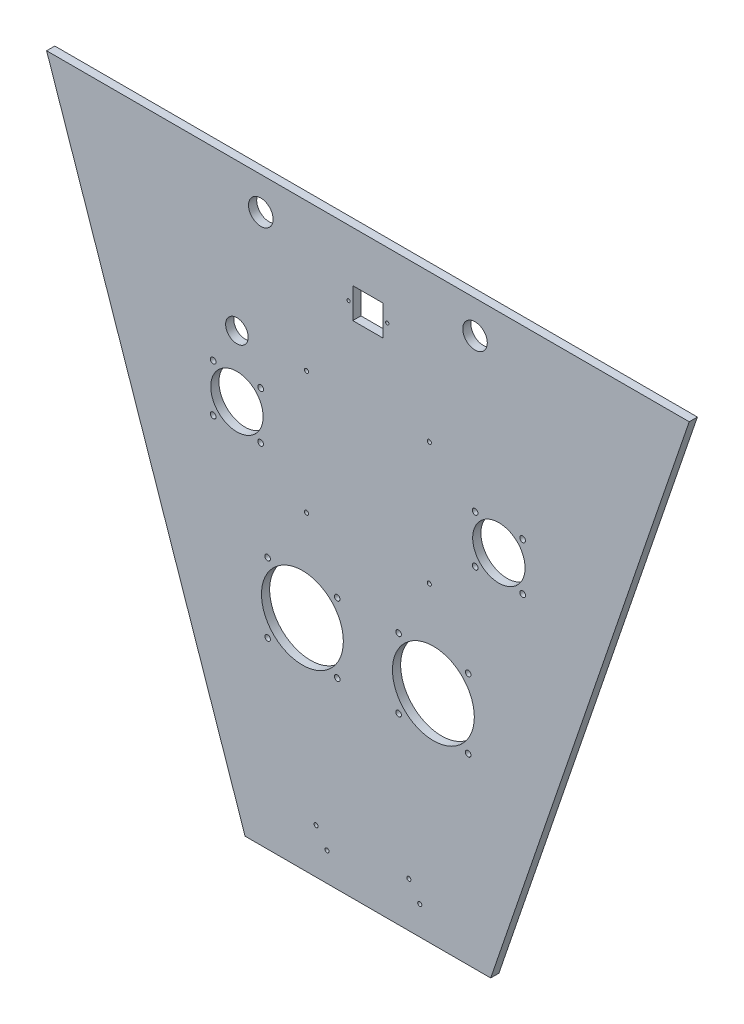
from build123d import *

# Parameters (mm, degrees)
BOSS_EXTRUDE1_DEPTH = 6.35
SKETCH2_R           = 1.5875
SKETCH2_W           = 23.495
SKETCH2_H           = 23.495
SKETCH2_R_2         = 8.763
SKETCH2_R_3         = 1.27
SKETCH2_R_4         = 2.159
SKETCH2_R_5         = 2.2225
SKETCH2_R_6         = 31.75
SKETCH2_R_7         = 20.32
SKETCH2_R_8         = 9.525
CUT_EXTRUDE1_DEPTH  = 7.35


with BuildPart() as part:
    # Sketch1 → Boss-Extrude1 (new body)
    with BuildSketch(Plane.XY):
        Polygon((-249.2375, 225.334147625), (249.2375, 225.334147625), (95.25, -225.334147625), (-95.25, -225.334147625), align=None)
    extrude(amount=BOSS_EXTRUDE1_DEPTH)

    # Sketch2 → Cut-Extrude1 (cut, through all)
    with BuildSketch(Plane.XY.offset(6.35)):
        with Locations((-47.625, 15.784147625)):
            Circle(SKETCH2_R)
        with Locations((-47.625, 111.034147625)):
            Circle(SKETCH2_R)
        with Locations((47.625, 15.784147625)):
            Circle(SKETCH2_R)
        with Locations((47.625, 111.034147625)):
            Circle(SKETCH2_R)
        with Locations((0, 174.534147625)):
            Rectangle(SKETCH2_W, SKETCH2_H)
        with Locations((-101.6, 111.034147625)):
            Circle(SKETCH2_R_2)
        with Locations((15, 174.534147625)):
            Circle(SKETCH2_R_3)
        with Locations((-15, 174.534147625)):
            Circle(SKETCH2_R_3)
        with Locations((-40.216666667, -190.409147625)):
            Circle(SKETCH2_R)
        with Locations((-31.75, -203.109147625)):
            Circle(SKETCH2_R)
        with Locations((31.75, -190.409147625)):
            Circle(SKETCH2_R)
        with Locations((40.216666667, -203.109147625)):
            Circle(SKETCH2_R)
        with Locations((-77.7875, -29.409256694)):
            Circle(SKETCH2_R_4)
        with Locations((-23.8125, -29.409256694)):
            Circle(SKETCH2_R_4)
        with Locations((-77.7875, -83.384256694)):
            Circle(SKETCH2_R_4)
        with Locations((-23.8125, -83.384256694)):
            Circle(SKETCH2_R_4)
        with Locations((-83.185, 44.994147625)):
            Circle(SKETCH2_R_5)
        with Locations((-50.8, -56.396756694)):
            Circle(SKETCH2_R_6)
        with Locations((-120.015, 44.994147625)):
            Circle(SKETCH2_R_5)
        with Locations((-120.015, 81.824147625)):
            Circle(SKETCH2_R_5)
        with Locations((-83.185, 81.824147625)):
            Circle(SKETCH2_R_5)
        with Locations((-101.6, 63.409147625)):
            Circle(SKETCH2_R_7)
        with Locations((120.015, 44.994147625)):
            Circle(SKETCH2_R_5)
        with Locations((83.185, 44.994147625)):
            Circle(SKETCH2_R_5)
        with Locations((83.185, 81.824147625)):
            Circle(SKETCH2_R_5)
        with Locations((-83.079166667, 199.934147625)):
            Circle(SKETCH2_R_8)
        with Locations((83.079166667, 199.934147625)):
            Circle(SKETCH2_R_8)
        with Locations((120.015, 81.824147625)):
            Circle(SKETCH2_R_5)
        with Locations((101.6, 63.409147625)):
            Circle(SKETCH2_R_7)
        with Locations((23.8125, -29.409256694)):
            Circle(SKETCH2_R_4)
        with Locations((77.7875, -29.409256694)):
            Circle(SKETCH2_R_4)
        with Locations((23.8125, -83.384256694)):
            Circle(SKETCH2_R_4)
        with Locations((77.7875, -83.384256694)):
            Circle(SKETCH2_R_4)
        with Locations((50.8, -56.396756694)):
            Circle(SKETCH2_R_6)
    extrude(amount=-CUT_EXTRUDE1_DEPTH, mode=Mode.SUBTRACT)


solid = part.part
